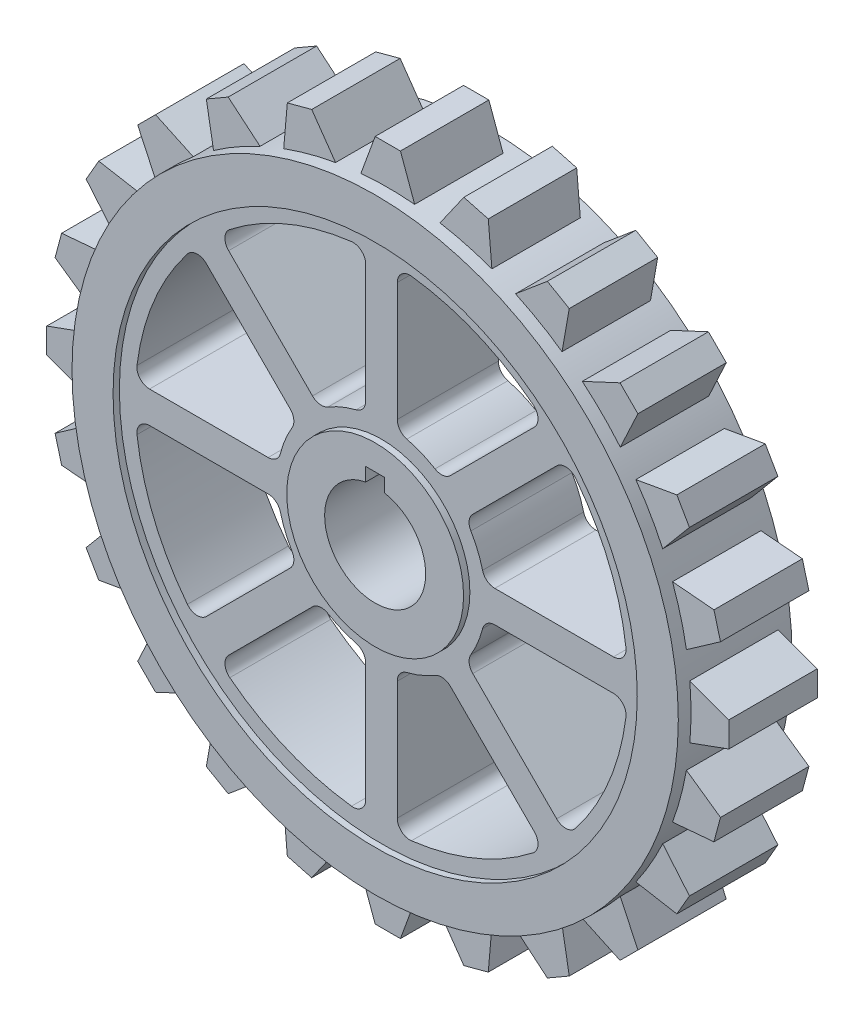
from build123d import *

# Parameters (mm, degrees)
SKETCH1_R           = 48
BOSS_EXTRUDE2_DEPTH = 9
SKETCH2_R           = 41.5
SKETCH2_R_2         = 14
CUT_EXTRUDE1_DEPTH  = 1
SKETCH3_R           = 41.5
SKETCH3_R_2         = 14
CUT_EXTRUDE2_DEPTH  = 1
BOSS_EXTRUDE3_DEPTH = 7
CIRPATTERN1_COUNT   = 24


with BuildPart() as part:
    # Sketch1 → Boss-Extrude2 (new body, symmetric)
    with BuildSketch(Plane.XY):
        Circle(SKETCH1_R)
        with BuildLine():
            Line((-1.5, 10), (-1.5, 7.858116823))
            ThreePointArc((-1.5, 7.858116823), (0, -8), (1.5, 7.858116823))
            Line((1.5, 7.858116823), (1.5, 10))
            Line((1.5, 10), (-1.5, 10))
        make_face(mode=Mode.SUBTRACT)
        with BuildLine():
            Line((-2.5, 36.725331857), (-2.5, 17.944358445))
            ThreePointArc((-2.5, 17.944358445), (-2.923140309, 16.714109074), (-4.013513514, 16.004427802))
            ThreePointArc((-4.013513514, 16.004427802), (-6.314276634, 15.244012286), (-8.478856806, 14.15482205))
            ThreePointArc((-8.478856806, 14.15482205), (-9.751687534, 13.885632203), (-10.920810587, 14.456344493))
            Line((-10.920810587, 14.456344493), (-24.200964244, 27.73649815))
            ThreePointArc((-24.200964244, 27.73649815), (-24.7830355, 29.272559678), (-24.018466935, 30.726425859))
            ThreePointArc((-24.018466935, 30.726425859), (-14.924653862, 36.031301768), (-4.743243243, 38.71048493))
            ThreePointArc((-4.743243243, 38.71048493), (-3.174572991, 38.223077911), (-2.5, 36.725331857))
        make_face(mode=Mode.SUBTRACT)
        with BuildLine():
            Line((2.5, 17.944358445), (2.5, 36.725331857))
            ThreePointArc((2.5, 36.725331857), (3.174572991, 38.223077911), (4.743243243, 38.71048493))
            ThreePointArc((4.743243243, 38.71048493), (14.924653862, 36.031301768), (24.018466935, 30.726425859))
            ThreePointArc((24.018466935, 30.726425859), (24.7830355, 29.272559678), (24.200964244, 27.73649815))
            Line((24.200964244, 27.73649815), (10.920810587, 14.456344493))
            ThreePointArc((10.920810587, 14.456344493), (9.751687534, 13.885632203), (8.478856806, 14.15482205))
            ThreePointArc((8.478856806, 14.15482205), (6.314276634, 15.244012286), (4.013513514, 16.004427802))
            ThreePointArc((4.013513514, 16.004427802), (2.923140309, 16.714109074), (2.5, 17.944358445))
        make_face(mode=Mode.SUBTRACT)
        with BuildLine():
            Line((14.456344493, 10.920810587), (27.73649815, 24.200964244))
            ThreePointArc((27.73649815, 24.200964244), (29.272559678, 24.7830355), (30.726425859, 24.018466935))
            ThreePointArc((30.726425859, 24.018466935), (36.031301768, 14.924653862), (38.71048493, 4.743243243))
            ThreePointArc((38.71048493, 4.743243243), (38.223077911, 3.174572991), (36.725331857, 2.5))
            Line((36.725331857, 2.5), (17.944358445, 2.5))
            ThreePointArc((17.944358445, 2.5), (16.714109074, 2.923140309), (16.004427802, 4.013513514))
            ThreePointArc((16.004427802, 4.013513514), (15.244012286, 6.314276634), (14.15482205, 8.478856806))
            ThreePointArc((14.15482205, 8.478856806), (13.885632203, 9.751687534), (14.456344493, 10.920810587))
        make_face(mode=Mode.SUBTRACT)
        with BuildLine():
            Line((17.944358445, -2.5), (36.725331857, -2.5))
            ThreePointArc((36.725331857, -2.5), (38.223077911, -3.174572991), (38.71048493, -4.743243243))
            ThreePointArc((38.71048493, -4.743243243), (36.031301768, -14.924653862), (30.726425859, -24.018466935))
            ThreePointArc((30.726425859, -24.018466935), (29.272559678, -24.7830355), (27.73649815, -24.200964244))
            Line((27.73649815, -24.200964244), (14.456344493, -10.920810587))
            ThreePointArc((14.456344493, -10.920810587), (13.885632203, -9.751687534), (14.15482205, -8.478856806))
            ThreePointArc((14.15482205, -8.478856806), (15.244012286, -6.314276634), (16.004427802, -4.013513514))
            ThreePointArc((16.004427802, -4.013513514), (16.714109074, -2.923140309), (17.944358445, -2.5))
        make_face(mode=Mode.SUBTRACT)
        with BuildLine():
            Line((10.920810587, -14.456344493), (24.200964244, -27.73649815))
            ThreePointArc((24.200964244, -27.73649815), (24.7830355, -29.272559678), (24.018466935, -30.726425859))
            ThreePointArc((24.018466935, -30.726425859), (14.924653862, -36.031301768), (4.743243243, -38.71048493))
            ThreePointArc((4.743243243, -38.71048493), (3.174572991, -38.223077911), (2.5, -36.725331857))
            Line((2.5, -36.725331857), (2.5, -17.944358445))
            ThreePointArc((2.5, -17.944358445), (2.923140309, -16.714109074), (4.013513514, -16.004427802))
            ThreePointArc((4.013513514, -16.004427802), (6.314276634, -15.244012286), (8.478856806, -14.15482205))
            ThreePointArc((8.478856806, -14.15482205), (9.751687534, -13.885632203), (10.920810587, -14.456344493))
        make_face(mode=Mode.SUBTRACT)
        with BuildLine():
            Line((-2.5, -17.944358445), (-2.5, -36.725331857))
            ThreePointArc((-2.5, -36.725331857), (-3.174572991, -38.223077911), (-4.743243243, -38.71048493))
            ThreePointArc((-4.743243243, -38.71048493), (-14.924653862, -36.031301768), (-24.018466935, -30.726425859))
            ThreePointArc((-24.018466935, -30.726425859), (-24.7830355, -29.272559678), (-24.200964244, -27.73649815))
            Line((-24.200964244, -27.73649815), (-10.920810587, -14.456344493))
            ThreePointArc((-10.920810587, -14.456344493), (-9.751687534, -13.885632203), (-8.478856806, -14.15482205))
            ThreePointArc((-8.478856806, -14.15482205), (-6.314276634, -15.244012286), (-4.013513514, -16.004427802))
            ThreePointArc((-4.013513514, -16.004427802), (-2.923140309, -16.714109074), (-2.5, -17.944358445))
        make_face(mode=Mode.SUBTRACT)
        with BuildLine():
            Line((-14.456344493, -10.920810587), (-27.73649815, -24.200964244))
            ThreePointArc((-27.73649815, -24.200964244), (-29.272559678, -24.7830355), (-30.726425859, -24.018466935))
            ThreePointArc((-30.726425859, -24.018466935), (-36.031301768, -14.924653862), (-38.71048493, -4.743243243))
            ThreePointArc((-38.71048493, -4.743243243), (-38.223077911, -3.174572991), (-36.725331857, -2.5))
            Line((-36.725331857, -2.5), (-17.944358445, -2.5))
            ThreePointArc((-17.944358445, -2.5), (-16.714109074, -2.923140309), (-16.004427802, -4.013513514))
            ThreePointArc((-16.004427802, -4.013513514), (-15.244012286, -6.314276634), (-14.15482205, -8.478856806))
            ThreePointArc((-14.15482205, -8.478856806), (-13.885632203, -9.751687534), (-14.456344493, -10.920810587))
        make_face(mode=Mode.SUBTRACT)
        with BuildLine():
            Line((-17.944358445, 2.5), (-36.725331857, 2.5))
            ThreePointArc((-36.725331857, 2.5), (-38.223077911, 3.174572991), (-38.71048493, 4.743243243))
            ThreePointArc((-38.71048493, 4.743243243), (-36.031301768, 14.924653862), (-30.726425859, 24.018466935))
            ThreePointArc((-30.726425859, 24.018466935), (-29.272559678, 24.7830355), (-27.73649815, 24.200964244))
            Line((-27.73649815, 24.200964244), (-14.456344493, 10.920810587))
            ThreePointArc((-14.456344493, 10.920810587), (-13.885632203, 9.751687534), (-14.15482205, 8.478856806))
            ThreePointArc((-14.15482205, 8.478856806), (-15.244012286, 6.314276634), (-16.004427802, 4.013513514))
            ThreePointArc((-16.004427802, 4.013513514), (-16.714109074, 2.923140309), (-17.944358445, 2.5))
        make_face(mode=Mode.SUBTRACT)
    extrude(amount=BOSS_EXTRUDE2_DEPTH, both=True)

    # Sketch2 → Cut-Extrude1 (cut)
    with BuildSketch(Plane.XY.offset(9)):
        Circle(SKETCH2_R)
        Circle(SKETCH2_R_2, mode=Mode.SUBTRACT)
    extrude(amount=-CUT_EXTRUDE1_DEPTH, mode=Mode.SUBTRACT)

    # Sketch3 → Cut-Extrude2 (cut)
    with BuildSketch(Plane(origin=(0, 0, -9), x_dir=(-1, 0, 0), z_dir=(0, 0, -1))):
        Circle(SKETCH3_R)
        Circle(SKETCH3_R_2, mode=Mode.SUBTRACT)
    extrude(amount=-CUT_EXTRUDE2_DEPTH, mode=Mode.SUBTRACT)

    # Sketch4 → Boss-Extrude3 (add, symmetric)
    with BuildSketch(Plane.XY):
        with BuildLine():
            Line((-2, 54), (2, 54))
            Line((2, 54), (4.252519055, 47.81125476))
            ThreePointArc((4.252519055, 47.81125476), (0, 48), (-4.252519055, 47.81125476))
            Line((-4.252519055, 47.81125476), (-2, 54))
        make_face()
    boss_extrude3 = extrude(amount=BOSS_EXTRUDE3_DEPTH, both=True)

    # CirPattern1: Boss-Extrude3 ×24 about axis
    cirpattern1_axis = Axis((0, 0, 0), (0, 0, 1))
    for i in range(1, CIRPATTERN1_COUNT):
        add(boss_extrude3.rotate(cirpattern1_axis, i * 360 / CIRPATTERN1_COUNT))


solid = part.part
